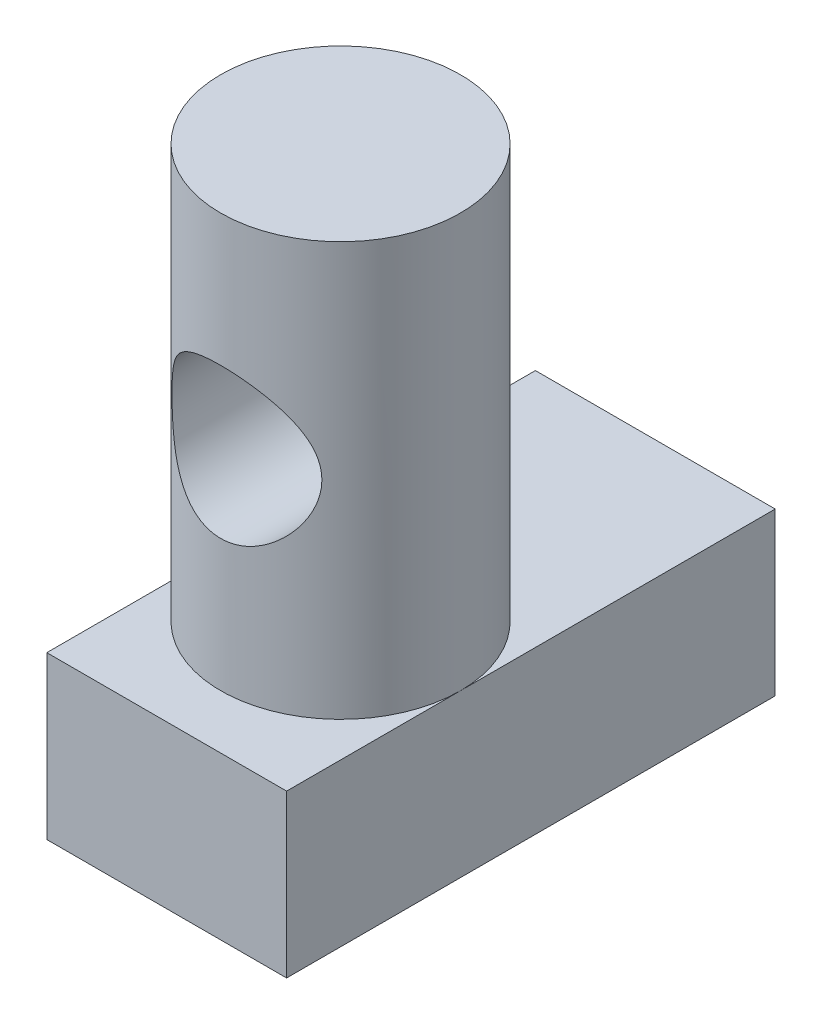
from build123d import *

# Parameters (mm, degrees)
SKETCH2_W         = 4
SKETCH2_H         = 8.15
BOTTOM_DEPTH      = 2.7
SKETCH3_R         = 2
TOP_DEPTH         = 6.9
SKETCH4_R         = 1.25
TENDON_HOLE_DEPTH = 13.5


with BuildPart() as part:
    # Sketch2 → bottom (new body)
    with BuildSketch(Plane(origin=(0, 0, 0), x_dir=(1, 0, 0), z_dir=(0, 1, 0))):
        Rectangle(SKETCH2_W, SKETCH2_H)
    extrude(amount=-BOTTOM_DEPTH)

    # Sketch3 → top (add)
    with BuildSketch(Plane(origin=(0, 0, 0), x_dir=(1, 0, 0), z_dir=(0, 1, 0))):
        with Locations((0, -1.175)):
            Circle(SKETCH3_R)
    extrude(amount=TOP_DEPTH)

    # Sketch4 → tendon hole (cut)
    with BuildSketch(Plane.XY.offset(4.075)):
        with Locations((0, 3.45)):
            Circle(SKETCH4_R)
    extrude(amount=-TENDON_HOLE_DEPTH, mode=Mode.SUBTRACT)


solid = part.part
